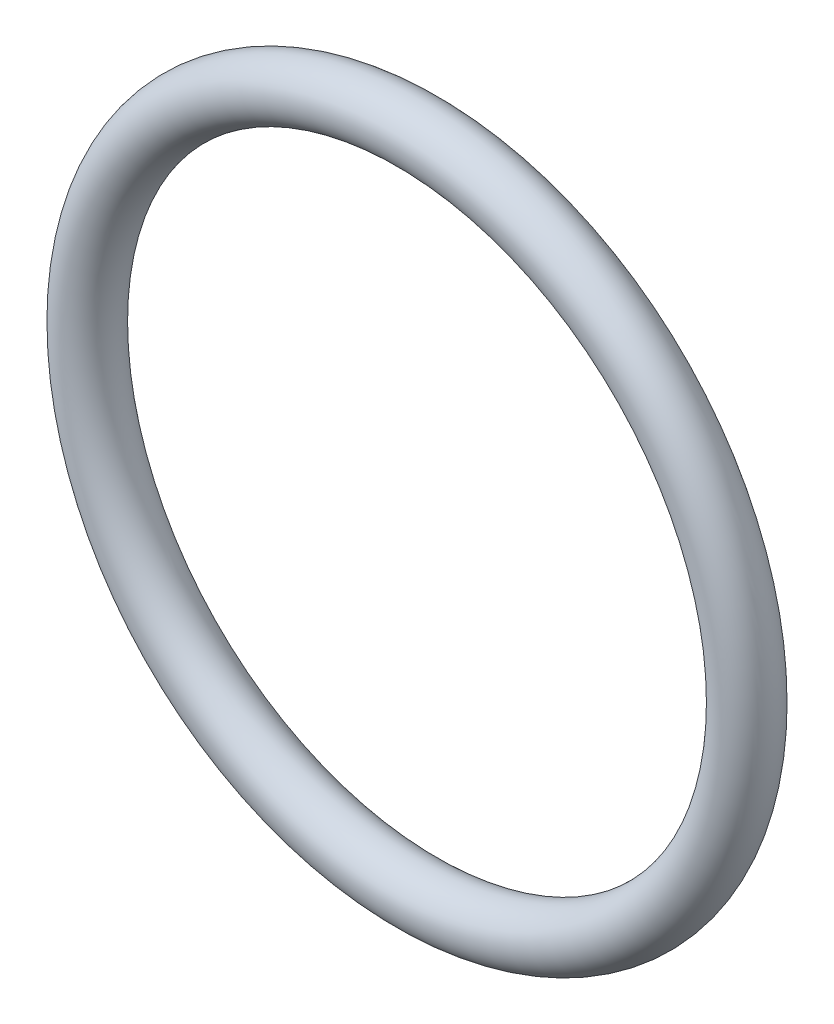
from build123d import *

# Parameters (mm, degrees)
SKETCH1_R = 0.889


with BuildPart() as part:
    # Sketch1 → Revolve1 (revolve)
    with BuildSketch(Plane(origin=(0, 0, 0), x_dir=(0, -1, 0), z_dir=(1, 0, 0))):
        with Locations((10.2743, 0)):
            Circle(SKETCH1_R)
    revolve(axis=Axis((0, 0, 0.889), (0, 0, -1)))


solid = part.part
